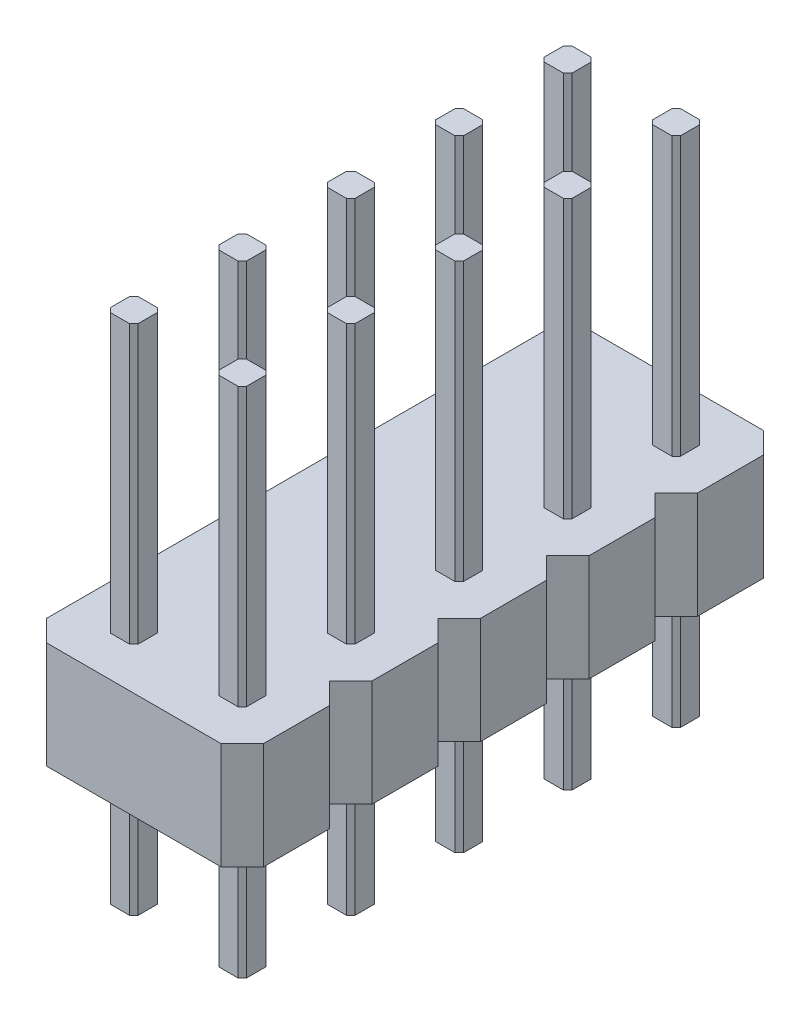
from build123d import *

# Parameters (mm, degrees)
BOSS_EXTRUDE1_DEPTH = 12
LPATTERN1_COUNT     = 2
LPATTERN1_PITCH     = 2.54
BOSS_EXTRUDE2_DEPTH = 2.5
LPATTERN2_COUNT     = 5
LPATTERN2_PITCH     = 2.54


with BuildPart() as part:
    # Sketch2 → Boss-Extrude1 (new body)
    with BuildSketch(Plane(origin=(0, 0, 0), x_dir=(1, 0, 0), z_dir=(0, 1, 0))):
        Polygon((-0.325, -0.225), (-0.225, -0.325), (0.225, -0.325), (0.325, -0.225), (0.325, 0.225), (0.225, 0.325), (-0.225, 0.325), (-0.325, 0.225), align=None)
    extrude(amount=BOSS_EXTRUDE1_DEPTH)


with BuildPart() as lpattern1_1:
    # LPattern1: pattern copy
    add(part.part.moved(Location(Vector(-1, 0, 0) * (1 * LPATTERN1_PITCH))))


with BuildPart() as part_1:
    add(part.part)

    add(lpattern1_1.part)  # Boss-Extrude2 merges LPattern1_1
    # Sketch3 → Boss-Extrude2 (add)
    with BuildSketch(Plane(origin=(0, 3, 0), x_dir=(-1, 0, 0), z_dir=(0, -1, 0))):
        Polygon((-1.27, 0.77), (-0.77, 1.27), (3.31, 1.27), (3.81, 0.77), (3.81, -0.77), (3.31, -1.27), (-0.77, -1.27), (-1.27, -0.77), align=None)
    extrude(amount=-BOSS_EXTRUDE2_DEPTH)


with BuildPart() as lpattern2_1:
    # LPattern2: pattern copy
    add(part_1.part.moved(Location(Vector(0, 0, 1) * (1 * LPATTERN2_PITCH))))


with BuildPart() as lpattern2_2:
    # LPattern2: pattern copy
    add(part_1.part.moved(Location(Vector(0, 0, 1) * (2 * LPATTERN2_PITCH))))


with BuildPart() as lpattern2_3:
    # LPattern2: pattern copy
    add(part_1.part.moved(Location(Vector(0, 0, 1) * (3 * LPATTERN2_PITCH))))


with BuildPart() as lpattern2_4:
    # LPattern2: pattern copy
    add(part_1.part.moved(Location(Vector(0, 0, 1) * (4 * LPATTERN2_PITCH))))


with BuildPart() as part_2:
    add(part_1.part)

    # Combine1: union LPattern2_1, LPattern2_2, LPattern2_3, LPattern2_4
    add(lpattern2_1.part)
    add(lpattern2_2.part)
    add(lpattern2_3.part)
    add(lpattern2_4.part)


solid = part_2.part
